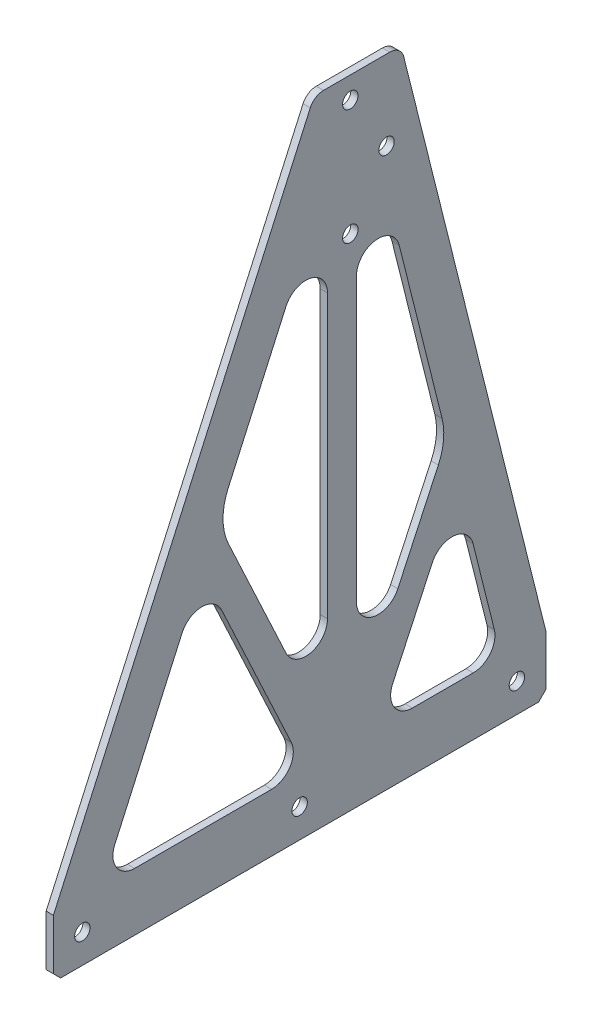
from build123d import *

# Parameters (mm, degrees)
BOSS_EXTRUDE1_DEPTH = 3.175
SKETCH3_R           = 3.3782
CUT_EXTRUDE2_DEPTH  = 4.175
SKETCH4_R           = 3.3782
CUT_EXTRUDE3_DEPTH  = 4.175
CHAMFER1_SIZE       = 3.175
CUT_EXTRUDE4_DEPTH  = 4.175


with BuildPart() as part:
    # Sketch1 → Boss-Extrude1 (new body)
    with BuildSketch(Plane(origin=(0, 0, 0), x_dir=(0, 0, -1), z_dir=(1, 0, 0))):
        with BuildLine():
            Line((118.405818623, 279.4), (147.442069819, 279.4))
            ThreePointArc((147.442069819, 279.4), (151.349937349, 278.055104531), (153.602474695, 274.590101219))
            Line((153.602474695, 274.590101219), (215.9, 25.4))
            Line((215.9, 25.4), (215.9, 0))
            Line((215.9, 0), (0, 0))
            Line((0, 0), (0, 25.4))
            Line((0, 25.4), (112.615117065, 275.655815701))
            ThreePointArc((112.615117065, 275.655815701), (114.95795187, 278.382421106), (118.405818623, 279.4))
        make_face()
    extrude(amount=BOSS_EXTRUDE1_DEPTH)

    # Sketch3 → Cut-Extrude2 (cut, through all)
    with BuildSketch(Plane(origin=(3.175, 0, 0), x_dir=(0, 0, -1), z_dir=(1, 0, 0))):
        with Locations((146.05, 244.475)):
            Circle(SKETCH3_R)
        with Locations((130.175, 219.075)):
            Circle(SKETCH3_R)
        with Locations((130.175, 269.875)):
            Circle(SKETCH3_R)
    extrude(amount=-CUT_EXTRUDE2_DEPTH, mode=Mode.SUBTRACT)

    # Sketch4 → Cut-Extrude3 (cut, through all)
    with BuildSketch(Plane(origin=(3.175, 0, 0), x_dir=(0, 0, -1), z_dir=(1, 0, 0))):
        with Locations((12.7, 12.7)):
            Circle(SKETCH4_R)
        with Locations((107.95, 12.7)):
            Circle(SKETCH4_R)
        with Locations((203.2, 12.7)):
            Circle(SKETCH4_R)
    extrude(amount=-CUT_EXTRUDE3_DEPTH, mode=Mode.SUBTRACT)

    # Chamfer1
    chamfer1_edges = [part.edges().sort_by_distance(p)[0] for p in [
        (1.5875, 0, -215.9),
        (1.5875, 0, 0),
    ]]
    chamfer(chamfer1_edges, length=CHAMFER1_SIZE)

    # Sketch5 → Cut-Extrude4 (cut, through all)
    with BuildSketch(Plane(origin=(3.175, 0, 0), x_dir=(0, 0, -1), z_dir=(1, 0, 0))):
        with BuildLine():
            Line((35.621183805, 25.4), (95.655352116, 25.4))
            ThreePointArc((95.655352116, 25.4), (103.688655638, 29.80722123), (104.287933788, 38.950438943))
            Line((104.287933788, 38.950438943), (73.736631302, 104.467918555))
            ThreePointArc((73.736631302, 104.467918555), (65.039859299, 109.967263315), (56.417997293, 104.351203163))
            Line((56.417997293, 104.351203163), (26.935131468, 38.833723552))
            ThreePointArc((26.935131468, 38.833723552), (27.622552146, 29.75319987), (35.621183805, 25.4))
        make_face()
        with BuildLine():
            Line((101.952143857, 205.538195526), (76.606881892, 149.21539116))
            ThreePointArc((76.606881892, 149.21539116), (74.370264914, 138.620954139), (76.749470333, 128.057624508))
            Line((76.749470333, 128.057624508), (102.005614522, 73.895648509))
            ThreePointArc((102.005614522, 73.895648509), (112.699783516, 68.621867985), (120.163196193, 77.921087453))
            Line((120.163196193, 77.921087453), (120.163196193, 201.629471974))
            ThreePointArc((120.163196193, 201.629471974), (112.637067937, 210.942373603), (101.952143857, 205.538195526))
        make_face()
        with BuildLine():
            Line((151.628803507, 203.939623803), (170.39715385, 128.866222433))
            ThreePointArc((170.39715385, 128.866222433), (171.039366508, 120.279332191), (168.775752137, 111.971313709))
            Line((168.775752137, 111.971313709), (151.020777865, 73.895648509))
            ThreePointArc((151.020777865, 73.895648509), (140.326608871, 68.621867985), (132.863196193, 77.921087453))
            Line((132.863196193, 77.921087453), (132.863196193, 201.629471974))
            ThreePointArc((132.863196193, 201.629471974), (141.224400607, 211.083106452), (151.628803507, 203.939623803))
        make_face()
        with BuildLine():
            Line((157.371040271, 25.4), (184.064314187, 25.4))
            ThreePointArc((184.064314187, 25.4), (191.571970984, 29.063198705), (193.304921501, 37.235151828))
            Line((193.304921501, 37.235151828), (183.988647407, 74.500248205))
            ThreePointArc((183.988647407, 74.500248205), (175.657972105, 81.671533437), (166.115458421, 76.21553532))
            Line((166.115458421, 76.21553532), (148.738458599, 38.950438943))
            ThreePointArc((148.738458599, 38.950438943), (149.337736749, 29.80722123), (157.371040271, 25.4))
        make_face()
    extrude(amount=-CUT_EXTRUDE4_DEPTH, mode=Mode.SUBTRACT)


solid = part.part
